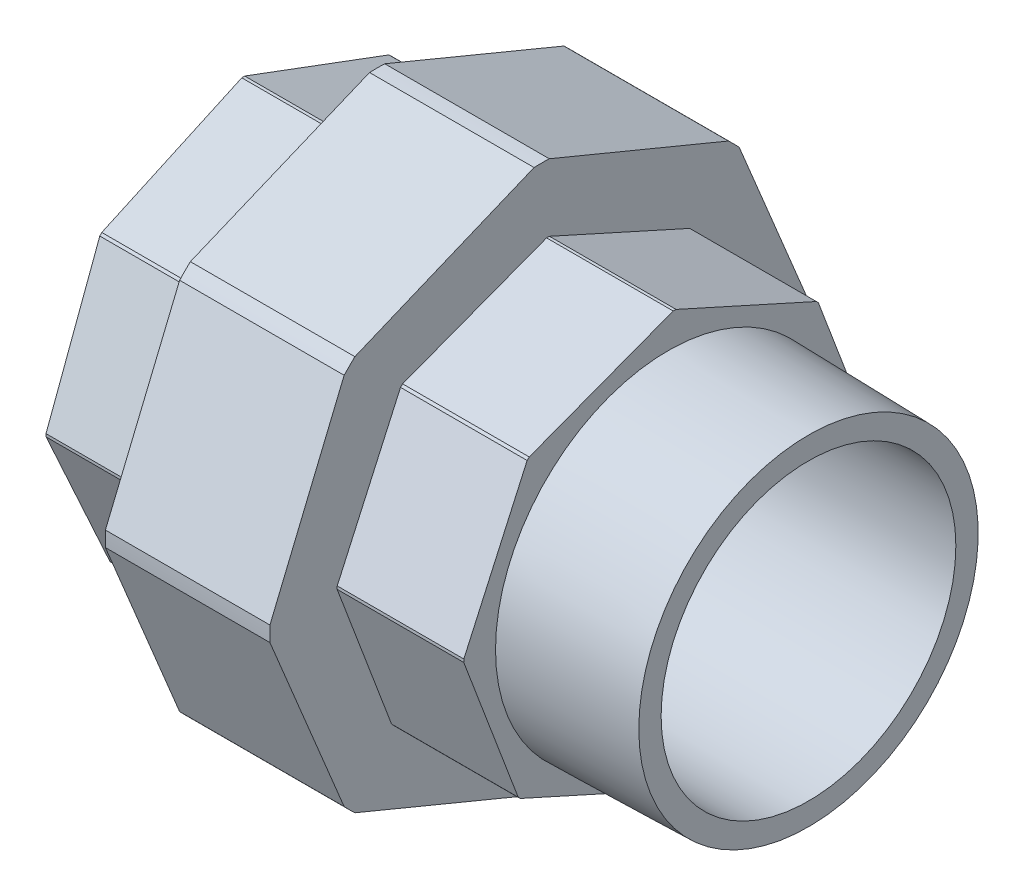
from build123d import *

# Parameters (mm, degrees)
SKETCH2_R          = 66.009585634
CUT_EXTRUDE1_DEPTH = 23
SKETCH4_R          = 31.856181498
CUT_EXTRUDE2_DEPTH = 17.7
SKETCH5_R          = 32.987885215
CUT_EXTRUDE3_DEPTH = 17.7


with BuildPart() as part:
    # Sketch1 → Revolve1 (revolve)
    with BuildSketch(Plane.XY):
        Polygon((0, -24.15), (12.7, -24.15), (12.7, -20.6), (62.8, -20.6), (78, -20.6), (78, -23.722326479), (58.4, -24.15), (58.4, -28.6), (40.7, -28.6), (40.7, -38), (17.7, -38), (17.7, -28.6), (0, -28.6), align=None)
    revolve(axis=Axis((0, 0, 0), (1, 0, 0)))

    # Sketch2 → Cut-Extrude1 (cut)
    with BuildSketch(Plane(origin=(40.7, 0, 0), x_dir=(0, 0, -1), z_dir=(1, 0, 0))):
        Circle(SKETCH2_R)
        Polygon((0, 38.42492311), (-27.170523698, 27.170523698), (-38.42492311, 0), (-27.170523698, -27.170523698), (0, -38.42492311), (27.170523698, -27.170523698), (38.42492311, 0), (27.170523698, 27.170523698), align=None, mode=Mode.SUBTRACT)
    extrude(amount=-CUT_EXTRUDE1_DEPTH, mode=Mode.SUBTRACT)

    # Sketch4 → Cut-Extrude2 (cut)
    with BuildSketch(Plane.ZY):
        Circle(SKETCH4_R)
        Polygon((1.020288253, 28.665241383), (-19.547933824, 20.990839308), (-28.665241383, 1.020288253), (-20.990839308, -19.547933824), (-1.020288253, -28.665241383), (19.547933824, -20.990839308), (28.665241383, -1.020288253), (20.990839308, 19.547933824), align=None, mode=Mode.SUBTRACT)
    extrude(amount=-CUT_EXTRUDE2_DEPTH, mode=Mode.SUBTRACT)

    # Sketch5 → Cut-Extrude3 (cut)
    with BuildSketch(Plane(origin=(58.4, 0, 0), x_dir=(0, 0, -1), z_dir=(1, 0, 0))):
        Circle(SKETCH5_R)
        Polygon((0.892984101, 28.66948955), (-19.640955361, 20.903825587), (-28.66948955, 0.892984101), (-20.903825587, -19.640955361), (-0.892984101, -28.66948955), (19.640955361, -20.903825587), (28.66948955, -0.892984101), (20.903825587, 19.640955361), align=None, mode=Mode.SUBTRACT)
    extrude(amount=-CUT_EXTRUDE3_DEPTH, mode=Mode.SUBTRACT)


solid = part.part
